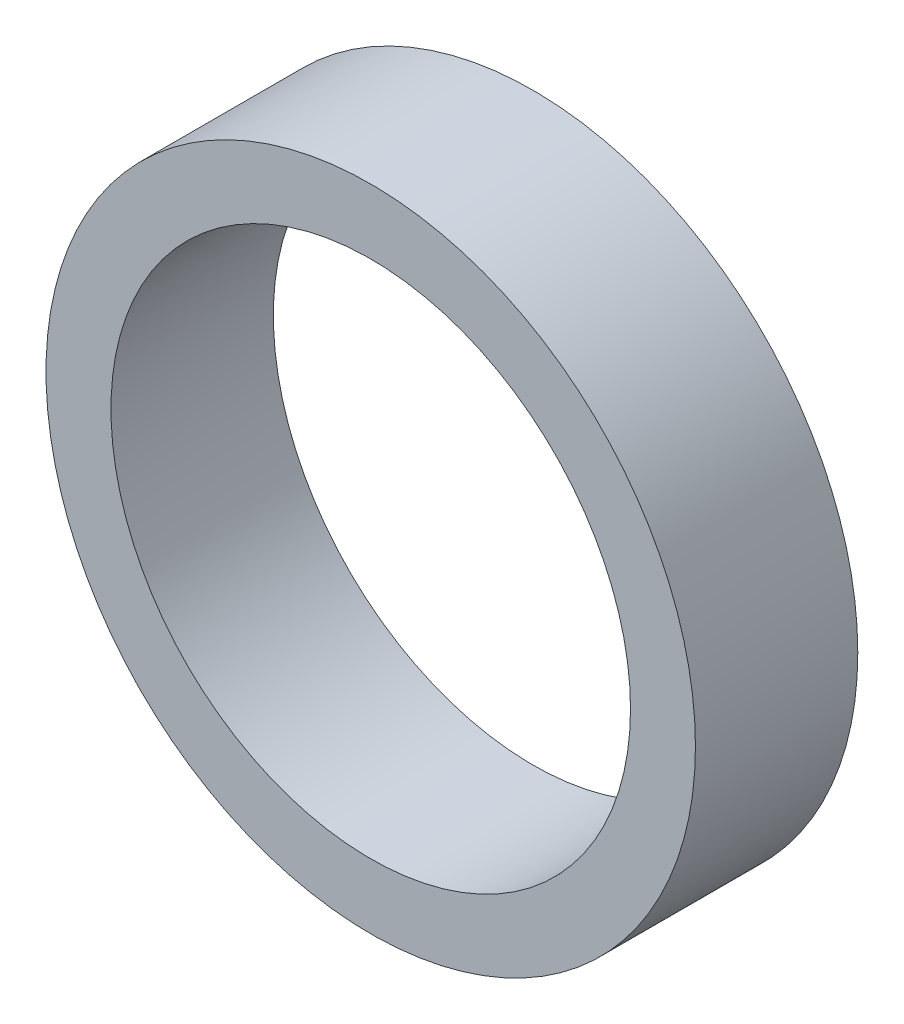
from build123d import *

# Parameters (mm, degrees)
SKETCH1_R           = 20
BOSS_EXTRUDE1_DEPTH = 10
SKETCH2_R           = 16
CUT_EXTRUDE1_DEPTH  = 11


with BuildPart() as part:
    # Sketch1 → Boss-Extrude1 (new body)
    with BuildSketch(Plane.XY):
        Circle(SKETCH1_R)
    extrude(amount=BOSS_EXTRUDE1_DEPTH)

    # Sketch2 → Cut-Extrude1 (cut, through all)
    with BuildSketch(Plane.XY.offset(10)):
        Circle(SKETCH2_R)
    extrude(amount=-CUT_EXTRUDE1_DEPTH, mode=Mode.SUBTRACT)


solid = part.part
